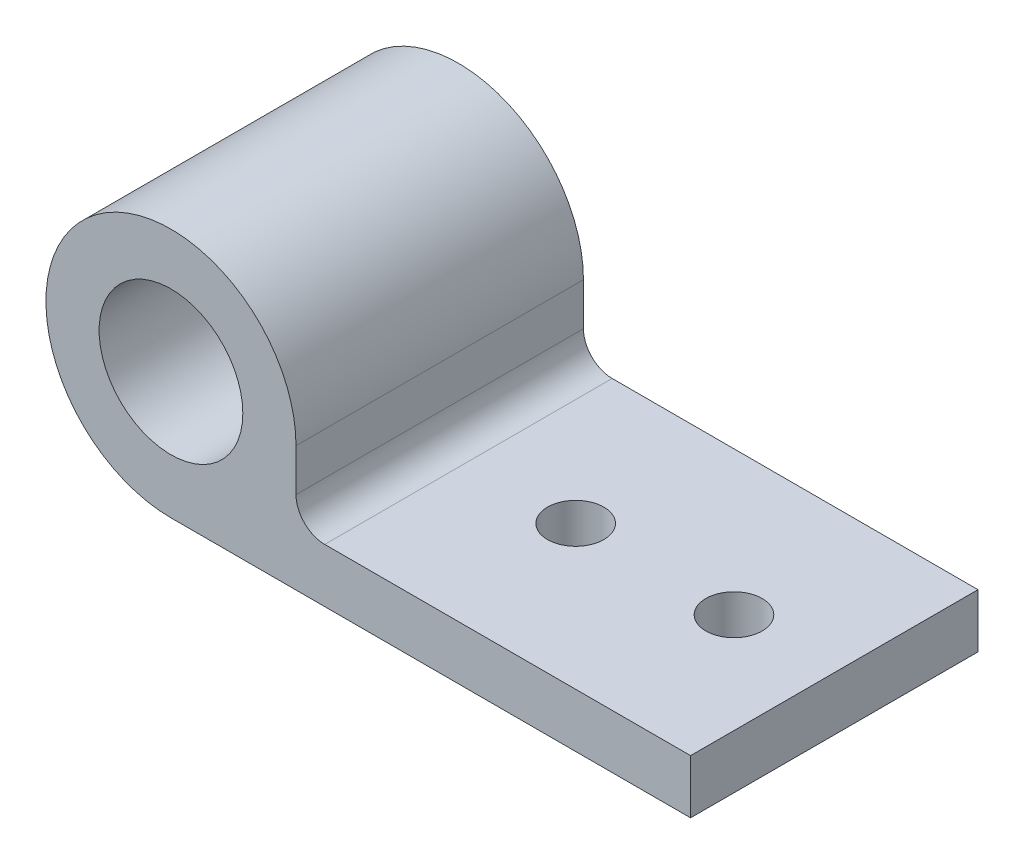
from build123d import *

# Parameters (mm, degrees)
SKETCH1_R           = 6.35
BOSS_EXTRUDE1_DEPTH = 25.4
FILLET1_R           = 2.54
SKETCH2_R           = 2.4892
CUT_EXTRUDE1_DEPTH  = 5.7625


with BuildPart() as part:
    # Sketch1 → Boss-Extrude1 (new body)
    with BuildSketch(Plane.XY):
        with BuildLine():
            Line((11.049, -6.2865), (11.049, 0))
            ThreePointArc((11.049, 0), (-7.812822825, 7.812822825), (0, -11.049))
            Line((0, -11.049), (45.91627088, -11.049))
            Line((45.91627088, -11.049), (45.91627088, -6.2865))
            Line((45.91627088, -6.2865), (11.049, -6.2865))
        make_face()
        with Locations((0, 0.127)):
            Circle(SKETCH1_R, mode=Mode.SUBTRACT)
    extrude(amount=BOSS_EXTRUDE1_DEPTH)

    # Fillet1
    fillet1_edges = [part.edges().sort_by_distance(p)[0] for p in [
        (11.049, -6.2865, 12.7),
    ]]
    fillet(fillet1_edges, radius=FILLET1_R)

    # Sketch2 → Cut-Extrude1 (cut, through all)
    with BuildSketch(Plane(origin=(0, -6.2865, 0), x_dir=(1, 0, 0), z_dir=(0, 1, 0))):
        with Locations((37.052858889, -12.7)):
            Circle(SKETCH2_R)
        with Locations((23.063244992, -12.7)):
            Circle(SKETCH2_R)
    extrude(amount=-CUT_EXTRUDE1_DEPTH, mode=Mode.SUBTRACT)


solid = part.part
